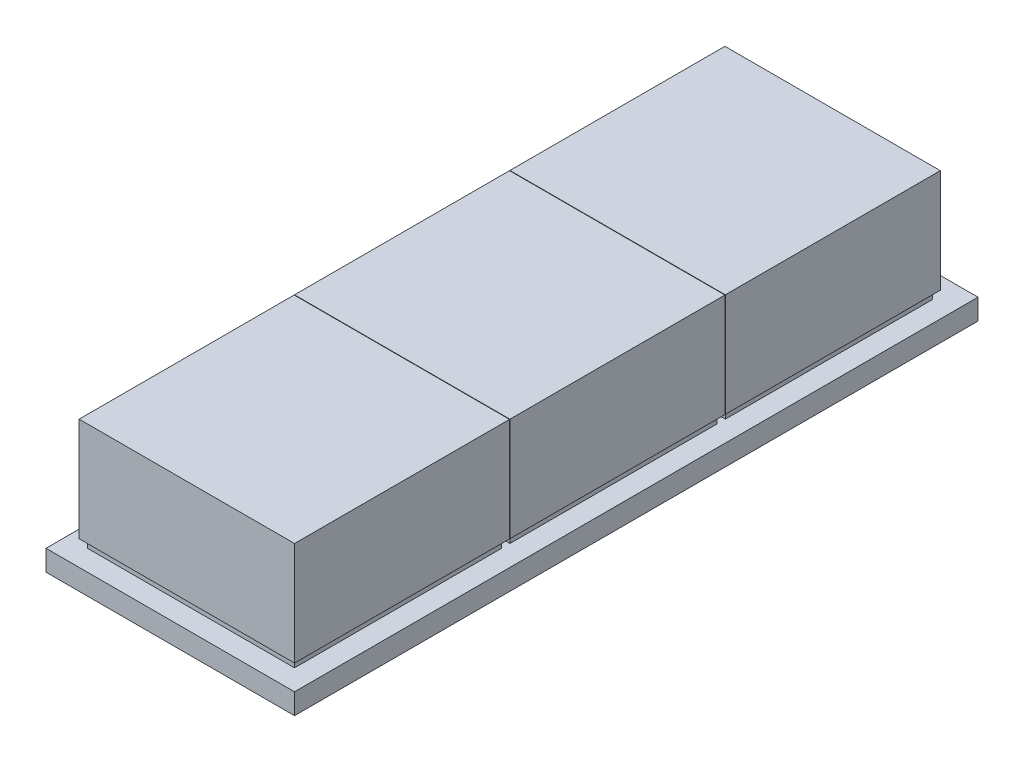
from build123d import *

# Parameters (mm, degrees)
SKETCH1_W           = 60
SKETCH1_H           = 165
BOSS_EXTRUDE1_DEPTH = 5
SKETCH2_W           = 50
SKETCH2_H           = 50
BOSS_EXTRUDE3_DEPTH = 2
LPATTERN1_COUNT     = 3
LPATTERN1_PITCH     = 52
SKETCH3_W           = 52
SKETCH3_H           = 51.9
BOSS_EXTRUDE8_DEPTH = 25
LPATTERN5_COUNT     = 3
LPATTERN5_PITCH     = 52


with BuildPart() as part:
    # Sketch1 → Boss-Extrude1 (new body)
    with BuildSketch(Plane(origin=(0, 0, 0), x_dir=(1, 0, 0), z_dir=(0, 1, 0))):
        Rectangle(SKETCH1_W, SKETCH1_H)
    extrude(amount=BOSS_EXTRUDE1_DEPTH)

    # Sketch2 → Boss-Extrude3 (add)
    with BuildSketch(Plane(origin=(0, 5, 0), x_dir=(1, 0, 0), z_dir=(0, 1, 0))):
        with Locations((0, -52.5)):
            Rectangle(SKETCH2_W, SKETCH2_H)
    boss_extrude3 = extrude(amount=BOSS_EXTRUDE3_DEPTH)

    # LPattern1: Boss-Extrude3 ×3
    with Locations(*[(0, 0, -i * LPATTERN1_PITCH) for i in range(1, LPATTERN1_COUNT)]):
        add(boss_extrude3)

    # Sketch3 → Boss-Extrude8 (add)
    with BuildSketch(Plane(origin=(0, 7, 0), x_dir=(1, 0, 0), z_dir=(0, 1, 0))):
        with Locations((0, -52.55)):
            Rectangle(SKETCH3_W, SKETCH3_H)
    boss_extrude8 = extrude(amount=BOSS_EXTRUDE8_DEPTH)

    # LPattern5: Boss-Extrude8 ×3
    with Locations(*[(0, 0, -i * LPATTERN5_PITCH) for i in range(1, LPATTERN5_COUNT)]):
        add(boss_extrude8)


solid = part.part
